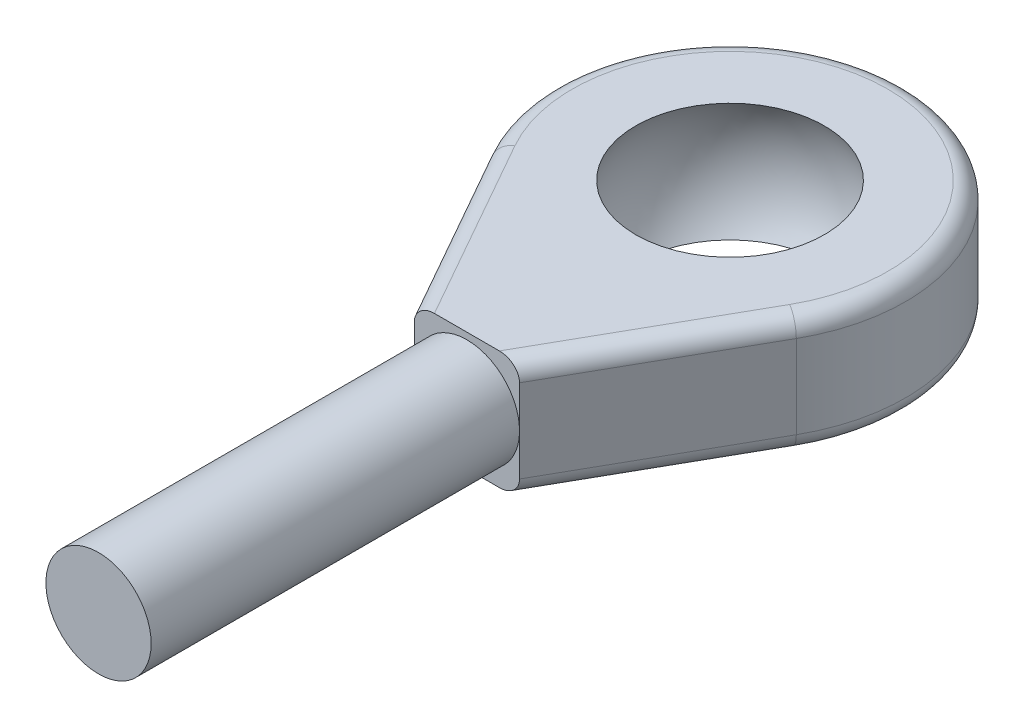
from build123d import *

# Parameters (mm, degrees)
EXTRUDE_1_DEPTH = 3.375
FILLET_1_R      = 1
SKETCH_3_R      = 3
EXTRUDE_2_DEPTH = 21


with BuildPart() as part:
    # 草图1 → 凸台-拉伸1 (new body, symmetric)
    with BuildSketch(Plane(origin=(0, 0, 0), x_dir=(1, 0, 0), z_dir=(0, 1, 0))):
        with BuildLine():
            Line((-3, -15), (3, -15))
            Line((3, -15), (8.702459553, -4.926174756))
            ThreePointArc((8.702459553, -4.926174756), (0, 10), (-8.702459553, -4.926174756))
            Line((-8.702459553, -4.926174756), (-3, -15))
        make_face()
    extrude(amount=EXTRUDE_1_DEPTH, both=True)

    # 草图2 → 切除-旋转1 (revolve, cut)
    with BuildSketch(Plane(origin=(0, 0, 0), x_dir=(0, 0, -1), z_dir=(1, 0, 0))):
        with BuildLine():
            Line((0, 6.35), (0, -6.35))
            ThreePointArc((0, -6.35), (6.35, 0), (0, 6.35))
        make_face()
    revolve(axis=Axis((0, 6.35, 0), (0, -1, 0)), mode=Mode.SUBTRACT)

    # 圆角1
    fillet_1_edges = [part.edges().sort_by_distance(p)[0] for p in [
        (5.851229777, 3.375, 9.963087378),
        (0, 3.375, -10),
        (-5.851229777, 3.375, 9.963087378),
        (0, -3.375, -10),
        (5.851229777, -3.375, 9.963087378),
        (-5.851229777, -3.375, 9.963087378),
    ]]
    fillet(fillet_1_edges, radius=FILLET_1_R)

    # 草图3 → 凸台-拉伸2 (add)
    with BuildSketch(Plane.XY.offset(15)):
        Circle(SKETCH_3_R)
    extrude(amount=EXTRUDE_2_DEPTH)


solid = part.part
